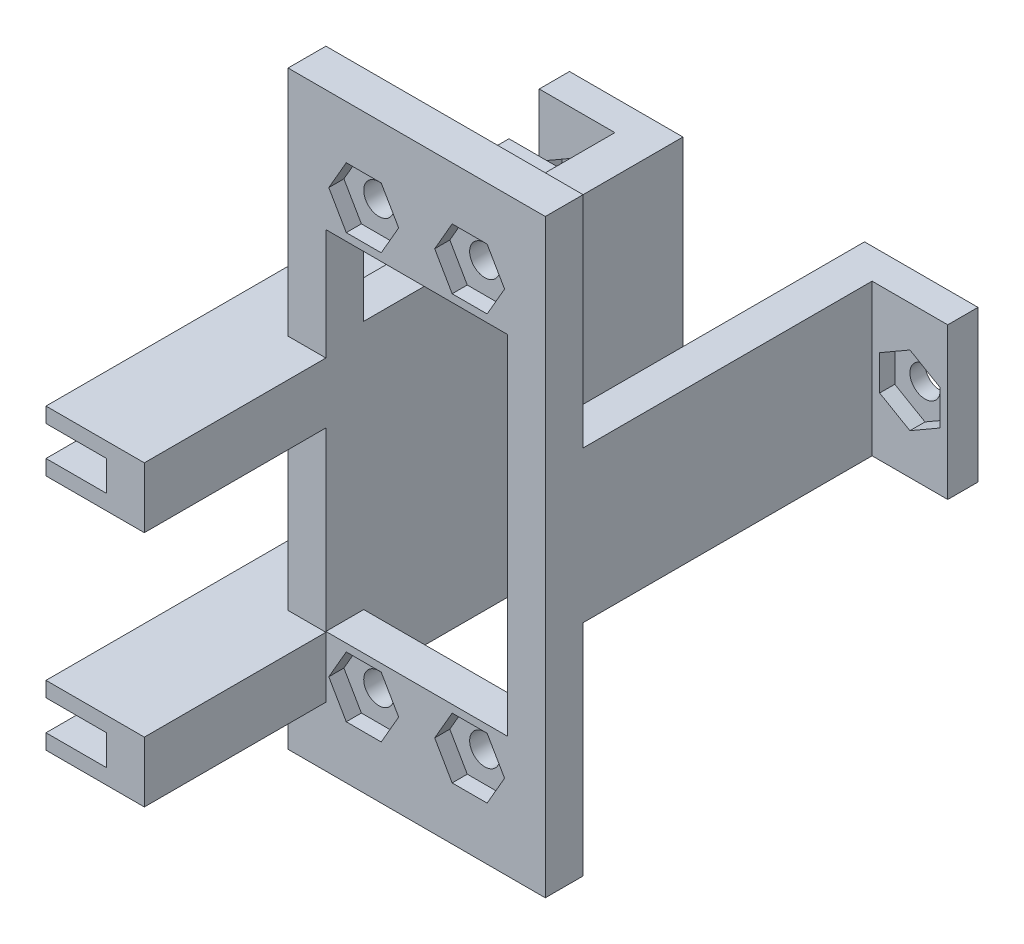
from build123d import *

# Parameters (mm, degrees)
SKETCH1_W                     = 17
SKETCH1_H                     = 39
SKETCH1_R                     = 1
SKETCH1_W_2                   = 12
SKETCH1_H_2                   = 23
SERVOBRACKET_DEPTH            = 2.5
SKETCH1_5_W                   = 2.5
SKETCH1_5_H                   = 10
SUPPORTLEGS_DEPTH             = 21.1
SKETCH2_W                     = 2
SKETCH2_H                     = 10
SUPPORTFOOT_DEPTH             = 5
BASEBOLTHOLE_START            = -3
SKETCH3_R                     = 1
BASEBOLTHOLE_DEPTH            = 25.6
SERVONUTSLOTS_DEPTH           = 1
BASENUTSLOTS_DEPTH            = 1
SKETCH6_W                     = 2.5
SKETCH6_H                     = 4
TUBEHOLDERBASE_DEPTH          = 12
SKETCH7_W                     = 4
SKETCH7_H                     = 1
TUBEHOLDERSTIFFENERRIBS_DEPTH = 30.6
SKETCH8_W                     = 1
SKETCH8_H                     = 1
SKETCH8_H_2                   = 0.25
TUBECLIPENTRANCES_DEPTH       = 2
SKETCH9_W                     = 1.5
SKETCH9_H                     = 1.5
TUBECLIPLOCKSLOT_DEPTH        = 0.6
TUBECLIPLOCKSLOT2_DEPTH       = 0.6
SUPPORTLEGEXTENSION_DEPTH     = 10.55
SKETCH8_4_W                   = 0.2
SKETCH8_4_H                   = 1.5
TUBECLIPLOCKCLEARANCE_DEPTH   = 0.5


with BuildPart() as part:
    # Sketch1 → ServoBracket (new body)
    with BuildSketch(Plane.XY):
        with Locations((0, 19.5)):
            Rectangle(SKETCH1_W, SKETCH1_H)
        with Locations((-3.5, 33.5)):
            Circle(SKETCH1_R, mode=Mode.SUBTRACT)
        with Locations((-3.5, 5.5)):
            Circle(SKETCH1_R, mode=Mode.SUBTRACT)
        with Locations((3.5, 5.5)):
            Circle(SKETCH1_R, mode=Mode.SUBTRACT)
        with Locations((3.5, 33.5)):
            Circle(SKETCH1_R, mode=Mode.SUBTRACT)
        with Locations((0, 19.5)):
            Rectangle(SKETCH1_W_2, SKETCH1_H_2, mode=Mode.SUBTRACT)
    extrude(amount=SERVOBRACKET_DEPTH)

    # Sketch1_5 → SupportLegs (add)
    with BuildSketch(Plane.XY):
        with Locations((-7.25, 19.5)):
            Rectangle(SKETCH1_5_W, SKETCH1_5_H)
        with Locations((7.25, 19.5)):
            Rectangle(SKETCH1_5_W, SKETCH1_5_H)
    extrude(amount=-SUPPORTLEGS_DEPTH)

    # Sketch2 → SupportFoot (add)
    with BuildSketch(Plane.ZY.offset(8.5)):
        with Locations((-20.1, 19.5)):
            Rectangle(SKETCH2_W, SKETCH2_H)
    supportfoot = extrude(amount=SUPPORTFOOT_DEPTH)

    # Sketch3 → BaseBoltHole (cut)
    with BuildSketch(Plane.XY.offset(-19.1).offset(BASEBOLTHOLE_START)):
        with Locations((-11, 19.5)):
            Circle(SKETCH3_R)
    basebolthole = extrude(amount=BASEBOLTHOLE_DEPTH, mode=Mode.SUBTRACT)

    # SupportFoot2: SupportFoot, BaseBoltHole across plane
    add(supportfoot.mirror(Plane(origin=(0, 0, 0), x_dir=(0, 0, 1), z_dir=(1, 0, 0))))
    add(basebolthole.mirror(Plane(origin=(0, 0, 0), x_dir=(0, 0, 1), z_dir=(1, 0, 0))), mode=Mode.SUBTRACT)

    # Sketch4 → ServoNutSlots (cut)
    with BuildSketch(Plane.XY.offset(2.5)):
        Polygon((-4.654700538, 7.5), (-2.345299462, 7.5), (-1.190598923, 5.5), (-2.345299462, 3.5), (-4.654700538, 3.5), (-5.809401077, 5.5), align=None)
        Polygon((-1.190598923, 33.5), (-2.345299462, 35.5), (-4.654700538, 35.5), (-5.809401077, 33.5), (-4.654700538, 31.5), (-2.345299462, 31.5), align=None)
        Polygon((2.345299462, 31.5), (1.190598923, 33.5), (2.345299462, 35.5), (4.654700538, 35.5), (5.809401077, 33.5), (4.654700538, 31.5), align=None)
        Polygon((4.654700538, 7.5), (2.345299462, 7.5), (1.190598923, 5.5), (2.345299462, 3.5), (4.654700538, 3.5), (5.809401077, 5.5), align=None)
    extrude(amount=-SERVONUTSLOTS_DEPTH, mode=Mode.SUBTRACT)

    # Sketch5 → BaseNutSlots (cut)
    with BuildSketch(Plane.XY.offset(-19.1)):
        Polygon((-11, 21.809401077), (-13, 20.654700538), (-13, 18.345299462), (-11, 17.190598923), (-9, 18.345299462), (-9, 20.654700538), align=None)
        Polygon((11, 21.809401077), (9, 20.654700538), (9, 18.345299462), (11, 17.190598923), (13, 18.345299462), (13, 20.654700538), align=None)
    extrude(amount=-BASENUTSLOTS_DEPTH, mode=Mode.SUBTRACT)

    # Sketch6 → TubeHolderBase (add)
    with BuildSketch(Plane.XY.offset(2.5)):
        with Locations((-7.25, 21.65)):
            Rectangle(SKETCH6_W, SKETCH6_H)
    tubeholderbase = extrude(amount=TUBEHOLDERBASE_DEPTH)

    # Sketch7 → TubeHolderStiffenerRibs (add)
    with BuildSketch(Plane.XY.offset(14.5)):
        with Locations((-10.5, 23.15)):
            Rectangle(SKETCH7_W, SKETCH7_H)
        with Locations((-10.5, 20.15)):
            Rectangle(SKETCH7_W, SKETCH7_H)
    tubeholderstiffenerribs = extrude(amount=-TUBEHOLDERSTIFFENERRIBS_DEPTH)

    # TubeHolder2: TubeHolderBase, TubeHolderStiffenerRibs across plane
    add(tubeholderbase.mirror(Plane.ZX.offset(13.8)))
    add(tubeholderstiffenerribs.mirror(Plane.ZX.offset(13.8)))

    # Sketch8 → TubeClipEntrances (cut)
    with BuildSketch(Plane.ZY.offset(8.5)):
        with Locations((11.1, 21.65)):
            Rectangle(SKETCH8_W, SKETCH8_H)
        with Locations((11.1, 22.275)):
            Rectangle(SKETCH8_W, SKETCH8_H_2)
        with Locations((11.1, 21.025)):
            Rectangle(SKETCH8_W, SKETCH8_H_2)
        with Locations((10.3, 6.575)):
            Rectangle(SKETCH8_W, SKETCH8_H_2)
        with Locations((10.3, 5.325)):
            Rectangle(SKETCH8_W, SKETCH8_H_2)
        with Locations((10.3, 5.95)):
            Rectangle(SKETCH8_W, SKETCH8_H)
    extrude(amount=-TUBECLIPENTRANCES_DEPTH, mode=Mode.SUBTRACT)

    # Sketch9 → TubeClipLockSlot (cut)
    with BuildSketch(Plane(origin=(0, 0, 11.6), x_dir=(-1, 0, 0), z_dir=(0, 0, -1))):
        with Locations((7.25, 21.65)):
            Rectangle(SKETCH9_W, SKETCH9_H)
    extrude(amount=-TUBECLIPLOCKSLOT_DEPTH, mode=Mode.SUBTRACT)

    # Sketch10 → TubeClipLockSlot2 (cut)
    with BuildSketch(Plane(origin=(0, 0, 10.8), x_dir=(-1, 0, 0), z_dir=(0, 0, -1))):
        Polygon((6.5, 5.45), (6.5, 5.2), (8, 5.2), (8, 6.7), (6.5, 6.7), align=None)
    extrude(amount=-TUBECLIPLOCKSLOT2_DEPTH, mode=Mode.SUBTRACT)

    # Sketch11 → SupportLegExtension (add)
    with BuildSketch(Plane.XZ.offset(-14.5)):
        Polygon((-6, 0), (-8.5, 0), (-8.5, -19.1), (-13.5, -19.1), (-13.5, -21.1), (-6, -21.1), align=None)
    extrude(amount=SUPPORTLEGEXTENSION_DEPTH)

    # Sketch8_4 → TubeClipLockClearance (cut)
    with BuildSketch(Plane.ZY.offset(8.5)):
        with Locations((10.9, 5.95)):
            Rectangle(SKETCH8_4_W, SKETCH8_4_H)
        with Locations((11.7, 21.65)):
            Rectangle(SKETCH8_4_W, SKETCH8_4_H)
    extrude(amount=-TUBECLIPLOCKCLEARANCE_DEPTH, mode=Mode.SUBTRACT)


solid = part.part
